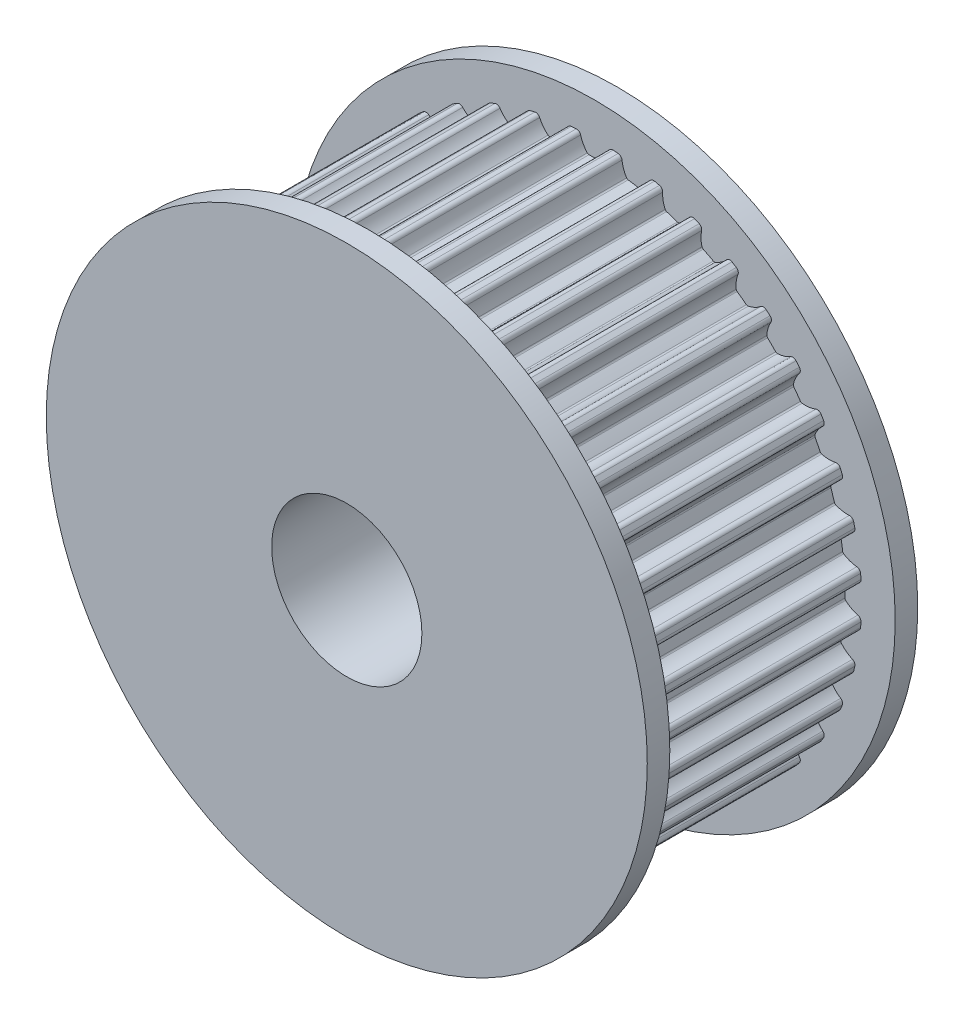
from build123d import *

# Parameters (mm, degrees)
SKETCH_1_R               = 17.765
EXTRUDE_1_DEPTH          = 7.5
CUT_EXTRUDE_START        = -16
CUT_EXTRUDE_1_DEPTH      = 17
PATTERN_CIRCULAR_1_COUNT = 40
SKETCH_3_R               = 20
EXTRUDE_2_DEPTH          = 1.5
SKETCH_9_R               = 20
EXTRUDE_3_DEPTH          = 1.5
SKETCH_4_R               = 5
CUT_EXTRUDE_2_DEPTH      = 19
SKETCH_10_R              = 2
CUT_EXTRUDE_3_DEPTH      = 21
SKETCH_11_R              = 2
CUT_EXTRUDE_4_DEPTH      = 21


with BuildPart() as part:
    # 草圖1 → 填料-伸長1 (new body, symmetric)
    with BuildSketch(Plane.XY):
        Circle(SKETCH_1_R)
    extrude(amount=EXTRUDE_1_DEPTH, both=True)

    # 草圖2 → 除料-伸長1 (cut)
    with BuildSketch(Plane.XY.offset(7.5).offset(CUT_EXTRUDE_START)):
        with BuildLine():
            ThreePointArc((-0.380313398, 16.650657246), (0, 16.655), (0.380313398, 16.650657246))
            ThreePointArc((0.380313398, 16.650657246), (0.44332155, 16.662959592), (0.495415763, 16.700477158))
            ThreePointArc((0.495415763, 16.700477158), (0.763361527, 17.081597098), (0.934577473, 17.514878115))
            ThreePointArc((0.934577473, 17.514878115), (1.042191202, 17.670992256), (1.224603763, 17.722741623))
            ThreePointArc((1.224603763, 17.722741623), (0, 17.765), (-1.224603763, 17.722741623))
            ThreePointArc((-1.224603763, 17.722741623), (-1.042191202, 17.670992256), (-0.934577473, 17.514878115))
            ThreePointArc((-0.934577473, 17.514878115), (-0.763361527, 17.081597098), (-0.495415763, 16.700477158))
            ThreePointArc((-0.495415763, 16.700477158), (-0.44332155, 16.662959592), (-0.380313398, 16.650657246))
        make_face()
    cut_extrude_1 = extrude(amount=CUT_EXTRUDE_1_DEPTH, mode=Mode.SUBTRACT)

    # 環狀複製排列1: 除料-伸長1 ×40 about axis
    pattern_circular_1_axis = Axis((0, 0, 0), (0, 0, 1))
    for i in range(1, PATTERN_CIRCULAR_1_COUNT):
        add(cut_extrude_1.rotate(pattern_circular_1_axis, i * 360 / PATTERN_CIRCULAR_1_COUNT), mode=Mode.SUBTRACT)

    # 草圖3 → 填料-伸長2 (add)
    with BuildSketch(Plane.XY.offset(7.5)):
        Circle(SKETCH_3_R)
    extrude(amount=EXTRUDE_2_DEPTH)

    # 草圖9 → 填料-伸長3 (add)
    with BuildSketch(Plane(origin=(0, 0, -7.5), x_dir=(-1, 0, 0), z_dir=(0, 0, -1))):
        Circle(SKETCH_9_R)
    extrude(amount=EXTRUDE_3_DEPTH)

    # 草圖4 → 除料-伸長2 (cut, through all)
    with BuildSketch(Plane.XY.offset(9)):
        Circle(SKETCH_4_R)
    extrude(amount=-CUT_EXTRUDE_2_DEPTH, mode=Mode.SUBTRACT)

    # 草圖10 → 除料-伸長3 (cut, through all)
    with BuildSketch(Plane(origin=(0, 0, 0), x_dir=(1, 0, 0), z_dir=(0, 1, 0))):
        Circle(SKETCH_10_R)
    extrude(amount=-CUT_EXTRUDE_3_DEPTH, mode=Mode.SUBTRACT)

    # 草圖11 → 除料-伸長4 (cut, through all)
    with BuildSketch(Plane(origin=(0, 0, 0), x_dir=(0, 0, -1), z_dir=(1, 0, 0))):
        Circle(SKETCH_11_R)
    extrude(amount=-CUT_EXTRUDE_4_DEPTH, mode=Mode.SUBTRACT)


solid = part.part
